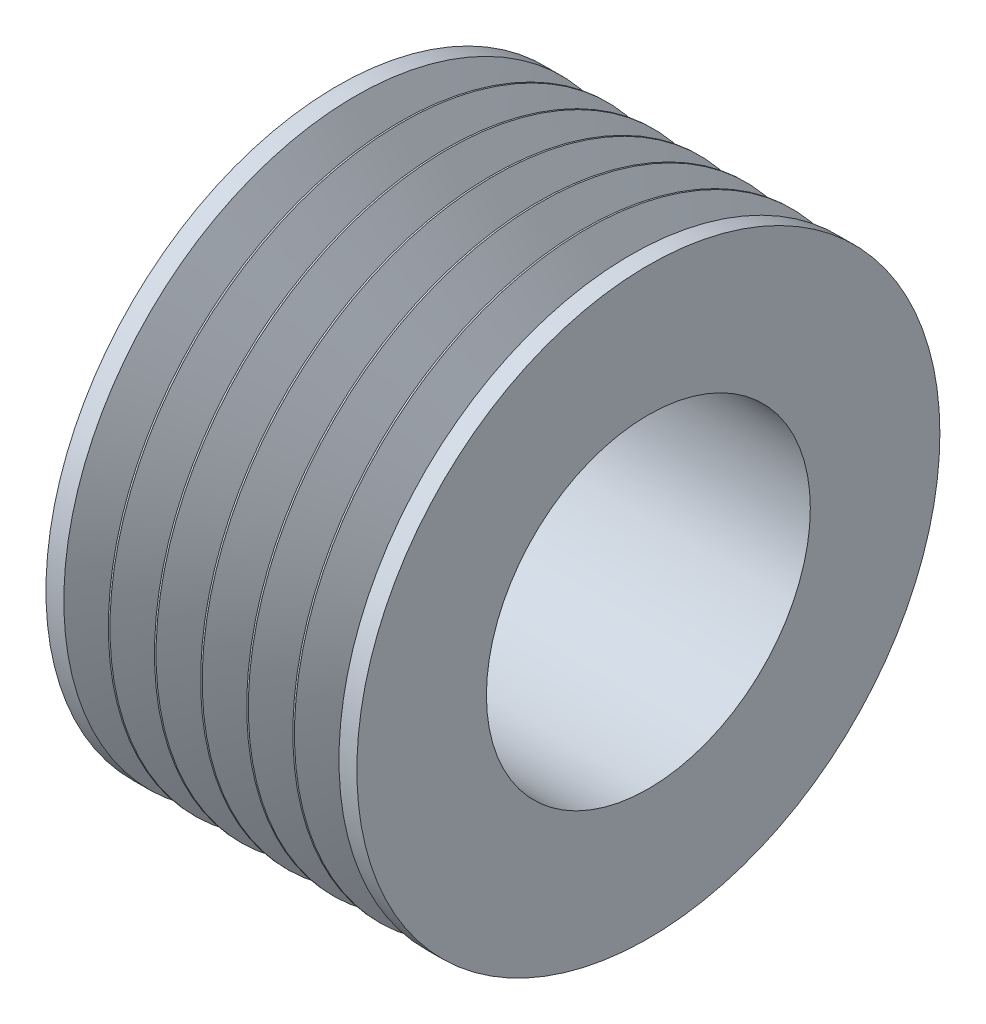
from build123d import *


with BuildPart() as part:
    # Эскиз1 → Повернуть1 (revolve)
    with BuildSketch(Plane.XY):
        with BuildLine():
            Line((0, 12.5), (-23.995742534, 12.5))
            Line((-23.995742534, 12.5), (-23.995742534, 22.5))
            Line((-23.995742534, 22.5), (-22.615742534, 22.5))
            Line((-22.615742534, 22.5), (-21.075273433, 19.540786391))
            ThreePointArc((-21.075273433, 19.540786391), (-20.897871267, 19.433136114), (-20.7204691, 19.540786391))
            Line((-20.7204691, 19.540786391), (-19.18, 22.5))
            Line((-19.18, 22.5), (-19.055742534, 22.5))
            Line((-19.055742534, 22.5), (-17.515273433, 19.540786391))
            ThreePointArc((-17.515273433, 19.540786391), (-17.337871267, 19.433136114), (-17.1604691, 19.540786391))
            Line((-17.1604691, 19.540786391), (-15.62, 22.5))
            Line((-15.62, 22.5), (-15.495742534, 22.5))
            Line((-15.495742534, 22.5), (-13.955273433, 19.540786391))
            ThreePointArc((-13.955273433, 19.540786391), (-13.777871267, 19.433136114), (-13.6004691, 19.540786391))
            Line((-13.6004691, 19.540786391), (-12.06, 22.5))
            Line((-12.06, 22.5), (-11.935742534, 22.5))
            Line((-11.935742534, 22.5), (-10.395273433, 19.540786391))
            ThreePointArc((-10.395273433, 19.540786391), (-10.217871267, 19.433136114), (-10.0404691, 19.540786391))
            Line((-10.0404691, 19.540786391), (-8.5, 22.5))
            Line((-8.5, 22.5), (-8.375742534, 22.5))
            Line((-8.375742534, 22.5), (-6.835273433, 19.540786391))
            ThreePointArc((-6.835273433, 19.540786391), (-6.657871267, 19.433136114), (-6.4804691, 19.540786391))
            Line((-6.4804691, 19.540786391), (-4.94, 22.5))
            Line((-4.94, 22.5), (-4.815742534, 22.5))
            Line((-4.815742534, 22.5), (-3.275273433, 19.540786391))
            ThreePointArc((-3.275273433, 19.540786391), (-3.097871267, 19.433136114), (-2.9204691, 19.540786391))
            Line((-2.9204691, 19.540786391), (-1.38, 22.5))
            Line((-1.38, 22.5), (0, 22.5))
            Line((0, 22.5), (0, 12.5))
        make_face()
    revolve(axis=Axis((63.754899424, 0, 0), (-1, 0, 0)))


solid = part.part
